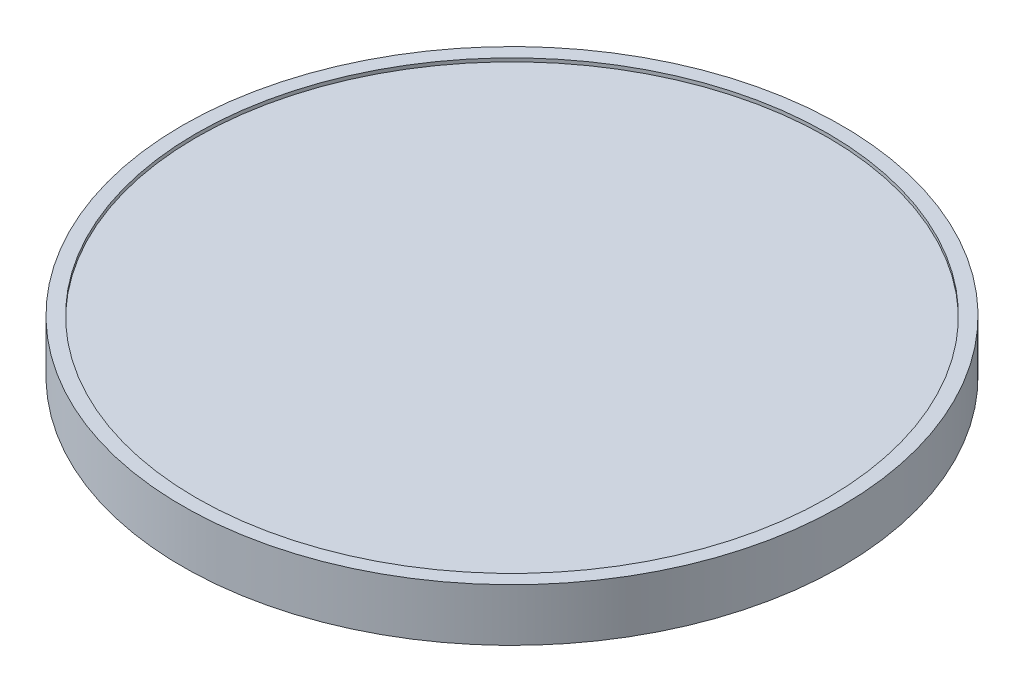
from build123d import *


with BuildPart() as part:
    # Sketch1 → Revolve1 (revolve)
    with BuildSketch(Plane.XY):
        Polygon((0, 0.66), (9.125, 0.66), (9.125, 0.76), (9.525, 0.76), (9.525, -0.76), (9.125, -0.76), (9.125, -0.66), (0, -0.66), align=None)
    revolve(axis=Axis((0, 5.73196658, 0), (0, -1, 0)))


solid = part.part
